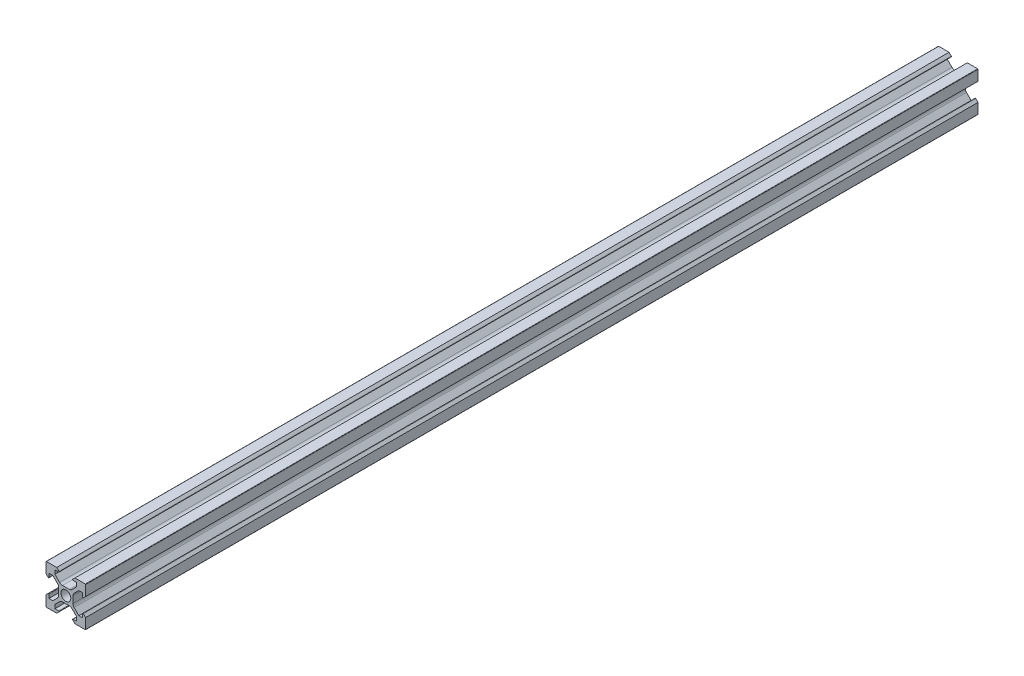
from build123d import *

# Parameters (mm, degrees)
ESBO_O1_R                = 2.5
RESSALTO_EXTRUS_O1_DEPTH = 450


with BuildPart() as part:
    # Esboço1 → Ressalto-extrusão1 (new body)
    with BuildSketch(Plane.XY):
        with BuildLine():
            Line((-4.6, -10), (-9.8, -10))
            ThreePointArc((-9.8, -10), (-9.941421356, -9.941421356), (-10, -9.8))
            Line((-10, -9.8), (-10, -4.6))
            Line((-10, -4.6), (-8.841421356, -3.441421356))
            ThreePointArc((-8.841421356, -3.441421356), (-8.623463314, -3.398066806), (-8.5, -3.582842712))
            Line((-8.5, -3.582842712), (-8.5, -5.5))
            Line((-8.5, -5.5), (-6.560660172, -5.5))
            Line((-6.560660172, -5.5), (-4.185786438, -3.125126266))
            ThreePointArc((-4.185786438, -3.125126266), (-3.752240935, -2.476279568), (-3.6, -1.710912703))
            Line((-3.6, -1.710912703), (-3.6, 1.710912703))
            ThreePointArc((-3.6, 1.710912703), (-3.752240935, 2.476279568), (-4.185786438, 3.125126266))
            Line((-4.185786438, 3.125126266), (-6.560660172, 5.5))
            Line((-6.560660172, 5.5), (-8.5, 5.5))
            Line((-8.5, 5.5), (-8.5, 3.582842712))
            ThreePointArc((-8.5, 3.582842712), (-8.623463314, 3.398066806), (-8.841421356, 3.441421356))
            Line((-8.841421356, 3.441421356), (-10, 4.6))
            Line((-10, 4.6), (-10, 9.8))
            ThreePointArc((-10, 9.8), (-9.941421356, 9.941421356), (-9.8, 10))
            Line((-9.8, 10), (-4.6, 10))
            Line((-4.6, 10), (-3.441421356, 8.841421356))
            ThreePointArc((-3.441421356, 8.841421356), (-3.398066806, 8.623463314), (-3.582842712, 8.5))
            Line((-3.582842712, 8.5), (-5.5, 8.5))
            Line((-5.5, 8.5), (-5.5, 6.560660172))
            Line((-5.5, 6.560660172), (-3.125126266, 4.185786438))
            ThreePointArc((-3.125126266, 4.185786438), (-2.476279568, 3.752240935), (-1.710912703, 3.6))
            Line((-1.710912703, 3.6), (1.710912703, 3.6))
            ThreePointArc((1.710912703, 3.6), (2.476279568, 3.752240935), (3.125126266, 4.185786438))
            Line((3.125126266, 4.185786438), (5.5, 6.560660172))
            Line((5.5, 6.560660172), (5.5, 8.5))
            Line((5.5, 8.5), (3.582842712, 8.5))
            ThreePointArc((3.582842712, 8.5), (3.398066806, 8.623463314), (3.441421356, 8.841421356))
            Line((3.441421356, 8.841421356), (4.6, 10))
            Line((4.6, 10), (9.8, 10))
            ThreePointArc((9.8, 10), (9.941421356, 9.941421356), (10, 9.8))
            Line((10, 9.8), (10, 4.6))
            Line((10, 4.6), (8.841421356, 3.441421356))
            ThreePointArc((8.841421356, 3.441421356), (8.623463314, 3.398066806), (8.5, 3.582842712))
            Line((8.5, 3.582842712), (8.5, 5.5))
            Line((8.5, 5.5), (6.560660172, 5.5))
            Line((6.560660172, 5.5), (4.185786438, 3.125126266))
            ThreePointArc((4.185786438, 3.125126266), (3.752240935, 2.476279568), (3.6, 1.710912703))
            Line((3.6, 1.710912703), (3.6, -1.710912703))
            ThreePointArc((3.6, -1.710912703), (3.752240935, -2.476279568), (4.185786438, -3.125126266))
            Line((4.185786438, -3.125126266), (6.560660172, -5.5))
            Line((6.560660172, -5.5), (8.5, -5.5))
            Line((8.5, -5.5), (8.5, -3.582842712))
            ThreePointArc((8.5, -3.582842712), (8.623463314, -3.398066806), (8.841421356, -3.441421356))
            Line((8.841421356, -3.441421356), (10, -4.6))
            Line((10, -4.6), (10, -9.8))
            ThreePointArc((10, -9.8), (9.941421356, -9.941421356), (9.8, -10))
            Line((9.8, -10), (4.6, -10))
            Line((4.6, -10), (3.441421356, -8.841421356))
            ThreePointArc((3.441421356, -8.841421356), (3.398066806, -8.623463314), (3.582842712, -8.5))
            Line((3.582842712, -8.5), (5.5, -8.5))
            Line((5.5, -8.5), (5.5, -6.560660172))
            Line((5.5, -6.560660172), (3.125126266, -4.185786438))
            ThreePointArc((3.125126266, -4.185786438), (2.476279568, -3.752240935), (1.710912703, -3.6))
            Line((1.710912703, -3.6), (-1.710912703, -3.6))
            ThreePointArc((-1.710912703, -3.6), (-2.476279568, -3.752240935), (-3.125126266, -4.185786438))
            Line((-3.125126266, -4.185786438), (-5.5, -6.560660172))
            Line((-5.5, -6.560660172), (-5.5, -8.5))
            Line((-5.5, -8.5), (-3.582842712, -8.5))
            ThreePointArc((-3.582842712, -8.5), (-3.398066806, -8.623463314), (-3.441421356, -8.841421356))
            Line((-3.441421356, -8.841421356), (-4.6, -10))
        make_face()
        Circle(ESBO_O1_R, mode=Mode.SUBTRACT)
    extrude(amount=RESSALTO_EXTRUS_O1_DEPTH)


solid = part.part
